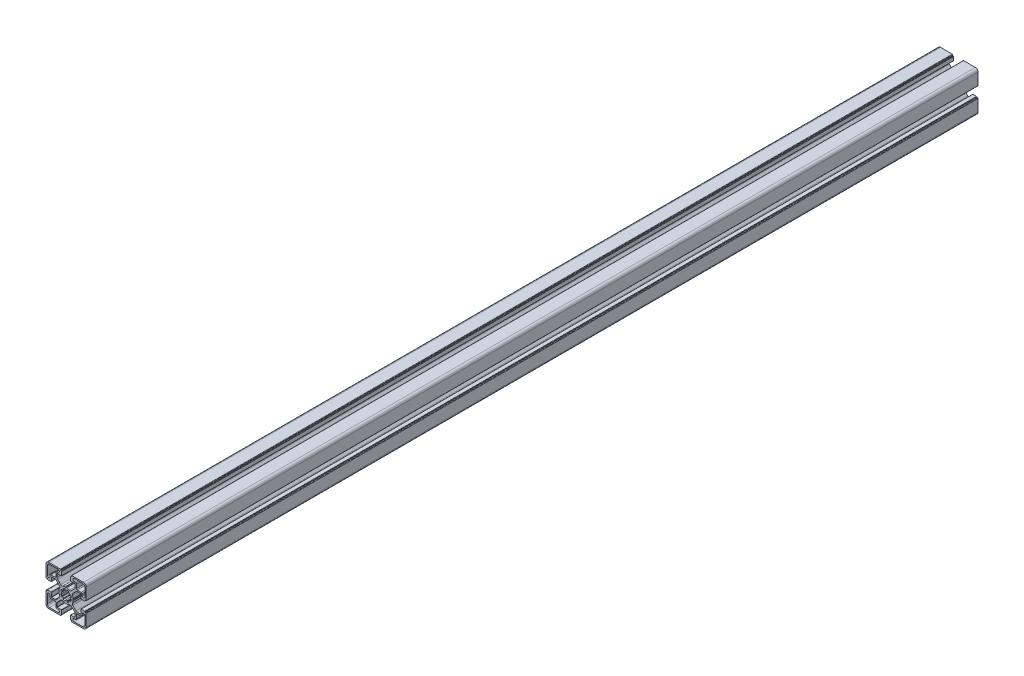
from build123d import *

# Parameters (mm, degrees)
BOSS_EXTRU_1_DEPTH = 1000


with BuildPart() as part:
    # Esquisse2 → Boss.-Extru.1 (new body)
    with BuildSketch(Plane.XY):
        with BuildLine():
            Line((-192.464705439, -351.135013575), (-192.030789329, -350.389251613))
            ThreePointArc((-192.030789329, -350.389251613), (-192.008099493, -350.33058749), (-192.004751867, -350.267777448))
            ThreePointArc((-192.004751867, -350.267777448), (-192.285035172, -348.883447185), (-192.804402464, -347.569983587))
            ThreePointArc((-192.804402464, -347.569983587), (-192.985908697, -346.38788866), (-192.44128198, -345.323147062))
            Line((-192.44128198, -345.323147062), (-188.874986025, -341.756855105))
            ThreePointArc((-188.874986025, -341.756855105), (-188.244141301, -341.335338521), (-187.500009401, -341.187321592))
            Line((-187.500009401, -341.187321592), (-183.687863463, -341.187321592))
            ThreePointArc((-183.687863463, -341.187321592), (-183.546441859, -341.245900338), (-183.487863113, -341.387321941))
            Line((-183.487863113, -341.387321941), (-183.487863113, -345.981828905))
            ThreePointArc((-183.487863113, -345.981828905), (-183.429284366, -346.12325051), (-183.287862762, -346.181829256))
            Line((-183.287862762, -346.181829256), (-179.285166009, -346.181829256))
            ThreePointArc((-179.285166009, -346.181829256), (-179.073034487, -346.093961503), (-178.985166733, -345.88182998))
            Line((-178.985166733, -345.88182998), (-178.985166733, -345.681839032))
            ThreePointArc((-178.985166733, -345.681839032), (-178.897298833, -345.469707156), (-178.685166958, -345.381839256))
            Line((-178.685166958, -345.381839256), (-178.0047864, -345.381839256))
            ThreePointArc((-178.0047864, -345.381839256), (-177.651233276, -345.235392756), (-177.504786776, -344.881839631))
            Line((-177.504786776, -344.881839631), (-177.504786776, -331.681827015))
            ThreePointArc((-177.504786776, -331.681827015), (-178.383465776, -329.560508257), (-180.504784534, -328.681829257))
            Line((-180.504784534, -328.681829257), (-193.629056903, -328.681829257))
            ThreePointArc((-193.629056903, -328.681829257), (-193.982610029, -328.828275756), (-194.129056529, -329.181828882))
            Line((-194.129056529, -329.181828882), (-194.129056529, -329.881829981))
            ThreePointArc((-194.129056529, -329.881829981), (-194.216924283, -330.093961503), (-194.429055805, -330.181829256))
            Line((-194.429055805, -330.181829256), (-194.70476714, -330.181829256))
            ThreePointArc((-194.70476714, -330.181829256), (-194.916898308, -330.269696863), (-195.004765915, -330.481828031))
            Line((-195.004765915, -330.481828031), (-195.004765915, -334.515030698))
            ThreePointArc((-195.004765915, -334.515030698), (-194.946187022, -334.656452656), (-194.804765065, -334.715031549))
            Line((-194.804765065, -334.715031549), (-190.099380697, -334.715031549))
            ThreePointArc((-190.099380697, -334.715031549), (-189.957959093, -334.773610295), (-189.899380347, -334.9150319))
            Line((-189.899380347, -334.9150319), (-189.899380347, -338.710260175))
            ThreePointArc((-189.899380347, -338.710260175), (-190.051621327, -339.47562727), (-190.48516696, -340.124474162))
            Line((-190.48516696, -340.124474162), (-194.059867926, -343.699175128))
            ThreePointArc((-194.059867926, -343.699175128), (-195.150164081, -344.214009408), (-196.338266679, -344.008553194))
            ThreePointArc((-196.338266679, -344.008553194), (-197.695629231, -343.467994797), (-199.128369878, -343.181829256))
            ThreePointArc((-199.128369878, -343.181829256), (-199.191201005, -343.184754557), (-199.250016338, -343.207049503))
            Line((-199.250016338, -343.207049503), (-199.892137456, -343.574906197))
            ThreePointArc((-199.892137456, -343.574906197), (-199.941802013, -343.622754392), (-200.004765916, -343.650889155))
            ThreePointArc((-200.004765916, -343.650889155), (-200.067729818, -343.622754392), (-200.117394375, -343.574906197))
            Line((-200.117394375, -343.574906197), (-200.759515492, -343.207049503))
            ThreePointArc((-200.759515492, -343.207049503), (-200.818330825, -343.184754557), (-200.881161953, -343.181829255))
            ThreePointArc((-200.881161953, -343.181829255), (-202.3139026, -343.467994797), (-203.671265152, -344.008553193))
            ThreePointArc((-203.671265152, -344.008553193), (-204.85936775, -344.214009407), (-205.949663904, -343.699175128))
            Line((-205.949663904, -343.699175128), (-209.52436487, -340.124474162))
            ThreePointArc((-209.52436487, -340.124474162), (-209.957910503, -339.475627269), (-210.110151485, -338.710260174))
            Line((-210.110151485, -338.710260174), (-210.110151485, -334.915031899))
            ThreePointArc((-210.110151485, -334.915031899), (-210.051572738, -334.773610295), (-209.910151134, -334.715031548))
            Line((-209.910151134, -334.715031548), (-205.204766766, -334.715031548))
            ThreePointArc((-205.204766766, -334.715031548), (-205.063344808, -334.656452656), (-205.004765915, -334.515030698))
            Line((-205.004765915, -334.515030698), (-205.004765915, -330.481828032))
            ThreePointArc((-205.004765915, -330.481828032), (-205.092633523, -330.269696863), (-205.304764692, -330.181829256))
            Line((-205.304764692, -330.181829256), (-205.580476025, -330.181829256))
            ThreePointArc((-205.580476025, -330.181829256), (-205.792607548, -330.093961502), (-205.880475302, -329.88182998))
            Line((-205.880475302, -329.88182998), (-205.880475302, -329.181828882))
            ThreePointArc((-205.880475302, -329.181828882), (-206.026921801, -328.828275756), (-206.380474927, -328.681829256))
            Line((-206.380474927, -328.681829256), (-219.504747296, -328.681829256))
            ThreePointArc((-219.504747296, -328.681829256), (-221.626066055, -329.560508256), (-222.504745055, -331.681827014))
            Line((-222.504745055, -331.681827014), (-222.504745055, -344.88183963))
            ThreePointArc((-222.504745055, -344.88183963), (-222.358298555, -345.235392756), (-222.00474543, -345.381839256))
            Line((-222.00474543, -345.381839256), (-221.324364871, -345.381839256))
            ThreePointArc((-221.324364871, -345.381839256), (-221.112232996, -345.469707157), (-221.024365096, -345.681839032))
            Line((-221.024365096, -345.681839032), (-221.024365096, -345.88182998))
            ThreePointArc((-221.024365096, -345.88182998), (-220.936497342, -346.093961503), (-220.724365819, -346.181829256))
            Line((-220.724365819, -346.181829256), (-216.721669067, -346.181829256))
            ThreePointArc((-216.721669067, -346.181829256), (-216.580247463, -346.12325051), (-216.521668717, -345.981828906))
            Line((-216.521668717, -345.981828906), (-216.521668717, -341.387321942))
            ThreePointArc((-216.521668717, -341.387321942), (-216.46308997, -341.245900338), (-216.321668366, -341.187321592))
            Line((-216.321668366, -341.187321592), (-212.509522428, -341.187321592))
            ThreePointArc((-212.509522428, -341.187321592), (-211.765390527, -341.335338522), (-211.134545803, -341.756855106))
            Line((-211.134545803, -341.756855106), (-207.568249848, -345.323147062))
            ThreePointArc((-207.568249848, -345.323147062), (-207.023623131, -346.38788866), (-207.205129364, -347.569983588))
            ThreePointArc((-207.205129364, -347.569983588), (-207.724496656, -348.883447186), (-208.004779961, -350.267777448))
            ThreePointArc((-208.004779961, -350.267777448), (-208.001432335, -350.33058749), (-207.978742499, -350.389251614))
            Line((-207.978742499, -350.389251614), (-207.54482639, -351.135013575))
            ThreePointArc((-207.54482639, -351.135013575), (-207.5390619, -351.158167493), (-207.536095855, -351.181843132))
            ThreePointArc((-207.536095855, -351.181843132), (-207.5390619, -351.20551877), (-207.54482639, -351.228672687))
            Line((-207.54482639, -351.228672687), (-207.978742499, -351.974434649))
            ThreePointArc((-207.978742499, -351.974434649), (-208.001432335, -352.033098773), (-208.004779962, -352.095908815))
            ThreePointArc((-208.004779962, -352.095908815), (-207.724496656, -353.480239077), (-207.205129364, -354.793702675))
            ThreePointArc((-207.205129364, -354.793702675), (-207.023623132, -355.975797603), (-207.568249848, -357.040539202))
            Line((-207.568249848, -357.040539202), (-211.134545804, -360.606831158))
            ThreePointArc((-211.134545804, -360.606831158), (-211.765390528, -361.028347742), (-212.509522429, -361.176364671))
            Line((-212.509522429, -361.176364671), (-216.321668366, -361.176364671))
            ThreePointArc((-216.321668366, -361.176364671), (-216.463089971, -361.117785925), (-216.521668717, -360.97636432))
            Line((-216.521668717, -360.97636432), (-216.521668717, -356.381857357))
            ThreePointArc((-216.521668717, -356.381857357), (-216.580247463, -356.240435753), (-216.721669067, -356.181857007))
            Line((-216.721669067, -356.181857007), (-220.72436582, -356.181857007))
            ThreePointArc((-220.72436582, -356.181857007), (-220.936497342, -356.26972476), (-221.024365096, -356.481856283))
            Line((-221.024365096, -356.481856283), (-221.024365096, -356.68184723))
            ThreePointArc((-221.024365096, -356.68184723), (-221.112232996, -356.893979106), (-221.324364871, -356.981847005))
            Line((-221.324364871, -356.981847005), (-222.004745429, -356.981847005))
            ThreePointArc((-222.004745429, -356.981847005), (-222.358298555, -357.128293506), (-222.504745055, -357.481846632))
            Line((-222.504745055, -357.481846632), (-222.504745055, -370.681859247))
            ThreePointArc((-222.504745055, -370.681859247), (-221.626066055, -372.803178006), (-219.504747296, -373.681857006))
            Line((-219.504747296, -373.681857006), (-206.380474927, -373.681857006))
            ThreePointArc((-206.380474927, -373.681857006), (-206.026921801, -373.535410506), (-205.880475301, -373.18185738))
            Line((-205.880475301, -373.18185738), (-205.880475301, -372.481856282))
            ThreePointArc((-205.880475301, -372.481856282), (-205.792607548, -372.269724759), (-205.580476025, -372.181857005))
            Line((-205.580476025, -372.181857005), (-205.304764691, -372.181857005))
            ThreePointArc((-205.304764691, -372.181857005), (-205.092633522, -372.093989398), (-205.004765915, -371.881858229))
            Line((-205.004765915, -371.881858229), (-205.004765915, -367.848655563))
            ThreePointArc((-205.004765915, -367.848655563), (-205.063344808, -367.707233605), (-205.204766766, -367.648654712))
            Line((-205.204766766, -367.648654712), (-209.910151134, -367.648654712))
            ThreePointArc((-209.910151134, -367.648654712), (-210.051572738, -367.590075966), (-210.110151485, -367.448654362))
            Line((-210.110151485, -367.448654362), (-210.110151485, -363.653426086))
            ThreePointArc((-210.110151485, -363.653426086), (-209.957910503, -362.888058992), (-209.524364871, -362.239212099))
            Line((-209.524364871, -362.239212099), (-205.949663905, -358.664511133))
            ThreePointArc((-205.949663905, -358.664511133), (-204.85936775, -358.149676855), (-203.671265152, -358.355133067))
            ThreePointArc((-203.671265152, -358.355133067), (-202.3139026, -358.895691464), (-200.881161954, -359.181857005))
            ThreePointArc((-200.881161954, -359.181857005), (-200.818330826, -359.178931703), (-200.759515493, -359.156636757))
            Line((-200.759515493, -359.156636757), (-200.117394376, -358.788780064))
            ThreePointArc((-200.117394376, -358.788780064), (-200.067729819, -358.740931869), (-200.004765916, -358.712797106))
            ThreePointArc((-200.004765916, -358.712797106), (-199.941802013, -358.740931869), (-199.892137456, -358.788780064))
            Line((-199.892137456, -358.788780064), (-199.250016339, -359.156636758))
            ThreePointArc((-199.250016339, -359.156636758), (-199.191201006, -359.178931704), (-199.128369878, -359.181857005))
            ThreePointArc((-199.128369878, -359.181857005), (-197.695629231, -358.895691464), (-196.338266679, -358.355133068))
            ThreePointArc((-196.338266679, -358.355133068), (-195.150164082, -358.149676855), (-194.059867927, -358.664511133))
            Line((-194.059867927, -358.664511133), (-190.48516696, -362.239212099))
            ThreePointArc((-190.48516696, -362.239212099), (-190.051621328, -362.888058992), (-189.899380348, -363.653426086))
            Line((-189.899380348, -363.653426086), (-189.899380348, -367.448654362))
            ThreePointArc((-189.899380348, -367.448654362), (-189.957959094, -367.590075965), (-190.099380697, -367.648654712))
            Line((-190.099380697, -367.648654712), (-194.804765066, -367.648654712))
            ThreePointArc((-194.804765066, -367.648654712), (-194.946187023, -367.707233605), (-195.004765916, -367.848655563))
            Line((-195.004765916, -367.848655563), (-195.004765916, -371.881858229))
            ThreePointArc((-195.004765916, -371.881858229), (-194.916898309, -372.093989397), (-194.70476714, -372.181857004))
            Line((-194.70476714, -372.181857004), (-194.429055806, -372.181857004))
            ThreePointArc((-194.429055806, -372.181857004), (-194.216924283, -372.269724758), (-194.12905653, -372.48185628))
            Line((-194.12905653, -372.48185628), (-194.12905653, -373.181857379))
            ThreePointArc((-194.12905653, -373.181857379), (-193.98261003, -373.535410505), (-193.629056903, -373.681857006))
            Line((-193.629056903, -373.681857006), (-180.504784534, -373.681857006))
            ThreePointArc((-180.504784534, -373.681857006), (-178.383465775, -372.803178005), (-177.504786775, -370.681859246))
            Line((-177.504786775, -370.681859246), (-177.504786775, -357.481846631))
            ThreePointArc((-177.504786775, -357.481846631), (-177.651233275, -357.128293504), (-178.004786402, -356.981847004))
            Line((-178.004786402, -356.981847004), (-178.685166959, -356.981847004))
            ThreePointArc((-178.685166959, -356.981847004), (-178.897298836, -356.893979105), (-178.985166735, -356.681847228))
            Line((-178.985166735, -356.681847228), (-178.985166735, -356.481856281))
            ThreePointArc((-178.985166735, -356.481856281), (-179.073034488, -356.269724759), (-179.28516601, -356.181857005))
            Line((-179.28516601, -356.181857005), (-183.287862762, -356.181857005))
            ThreePointArc((-183.287862762, -356.181857005), (-183.429284367, -356.240435752), (-183.487863113, -356.381857356))
            Line((-183.487863113, -356.381857356), (-183.487863113, -360.97636432))
            ThreePointArc((-183.487863113, -360.97636432), (-183.546441859, -361.117785924), (-183.687863463, -361.176364671))
            Line((-183.687863463, -361.176364671), (-187.500009401, -361.176364671))
            ThreePointArc((-187.500009401, -361.176364671), (-188.244141302, -361.028347742), (-188.874986026, -360.606831157))
            Line((-188.874986026, -360.606831157), (-192.441281982, -357.040539201))
            ThreePointArc((-192.441281982, -357.040539201), (-192.985908698, -355.975797602), (-192.804402465, -354.793702674))
            ThreePointArc((-192.804402465, -354.793702674), (-192.285035173, -353.480239077), (-192.004751867, -352.095908814))
            ThreePointArc((-192.004751867, -352.095908814), (-192.008099493, -352.033098772), (-192.030789329, -351.974434649))
            Line((-192.030789329, -351.974434649), (-192.464705438, -351.228672687))
            ThreePointArc((-192.464705438, -351.228672687), (-192.47046993, -351.20551877), (-192.473435973, -351.181843131))
            ThreePointArc((-192.473435973, -351.181843131), (-192.47046993, -351.158167492), (-192.464705439, -351.135013575))
        make_face()
        with BuildLine():
            Line((-195.08422015, -352.069665956), (-194.515035218, -352.16805429))
            ThreePointArc((-194.515035218, -352.16805429), (-194.165013852, -352.386136153), (-194.09791825, -352.793042574))
            ThreePointArc((-194.09791825, -352.793042574), (-194.353505931, -353.535154011), (-194.702268027, -354.238303673))
            ThreePointArc((-194.702268027, -354.238303673), (-195.035805071, -354.480613812), (-195.437988264, -354.390005633))
            Line((-195.437988264, -354.390005633), (-195.915053025, -354.058342475))
            ThreePointArc((-195.915053025, -354.058342475), (-196.474632965, -354.722769754), (-197.140765494, -355.280318651))
            Line((-197.140765494, -355.280318651), (-196.813454008, -355.744441346))
            ThreePointArc((-196.813454008, -355.744441346), (-196.720150548, -356.146118205), (-196.960380945, -356.481288596))
            ThreePointArc((-196.960380945, -356.481288596), (-197.665869942, -356.825320826), (-198.409694498, -357.075915978))
            ThreePointArc((-198.409694498, -357.075915978), (-198.816910196, -357.011432294), (-199.037244235, -356.662956066))
            Line((-199.037244235, -356.662956066), (-199.137377178, -356.106032077))
            ThreePointArc((-199.137377178, -356.106032077), (-200.004765915, -356.181843131), (-200.872154653, -356.106032077))
            Line((-200.872154653, -356.106032077), (-200.972287596, -356.662956066))
            ThreePointArc((-200.972287596, -356.662956066), (-201.192621634, -357.011432294), (-201.599837332, -357.075915978))
            ThreePointArc((-201.599837332, -357.075915978), (-202.343661888, -356.825320826), (-203.049150885, -356.481288596))
            ThreePointArc((-203.049150885, -356.481288596), (-203.289381283, -356.146118205), (-203.196077822, -355.744441346))
            Line((-203.196077822, -355.744441346), (-202.868766337, -355.280318651))
            ThreePointArc((-202.868766337, -355.280318651), (-203.534898866, -354.722769754), (-204.094478805, -354.058342475))
            Line((-204.094478805, -354.058342475), (-204.571543566, -354.390005633))
            ThreePointArc((-204.571543566, -354.390005633), (-204.97372676, -354.480613812), (-205.307263804, -354.238303673))
            ThreePointArc((-205.307263804, -354.238303673), (-205.6560259, -353.535154011), (-205.91161358, -352.793042574))
            ThreePointArc((-205.91161358, -352.793042574), (-205.844517979, -352.386136153), (-205.494496613, -352.16805429))
            Line((-205.494496613, -352.16805429), (-204.925311681, -352.069665956))
            ThreePointArc((-204.925311681, -352.069665956), (-205.004765916, -351.18184313), (-204.925311681, -350.294020305))
            Line((-204.925311681, -350.294020305), (-205.494496613, -350.195631971))
            ThreePointArc((-205.494496613, -350.195631971), (-205.844517979, -349.977550108), (-205.91161358, -349.570643686))
            ThreePointArc((-205.91161358, -349.570643686), (-205.6560259, -348.82853225), (-205.307263804, -348.125382588))
            ThreePointArc((-205.307263804, -348.125382588), (-204.97372676, -347.883072448), (-204.571543566, -347.973680627))
            Line((-204.571543566, -347.973680627), (-204.094478805, -348.305343785))
            ThreePointArc((-204.094478805, -348.305343785), (-203.534898866, -347.640916506), (-202.868766337, -347.08336761))
            Line((-202.868766337, -347.08336761), (-203.196077822, -346.619244915))
            ThreePointArc((-203.196077822, -346.619244915), (-203.289381283, -346.217568056), (-203.049150885, -345.882397665))
            ThreePointArc((-203.049150885, -345.882397665), (-202.343661888, -345.538365434), (-201.599837332, -345.287770282))
            ThreePointArc((-201.599837332, -345.287770282), (-201.192621634, -345.352253967), (-200.972287596, -345.700730195))
            Line((-200.972287596, -345.700730195), (-200.872154653, -346.257654184))
            ThreePointArc((-200.872154653, -346.257654184), (-200.004765915, -346.18184313), (-199.137377178, -346.257654184))
            Line((-199.137377178, -346.257654184), (-199.037244235, -345.700730195))
            ThreePointArc((-199.037244235, -345.700730195), (-198.816910196, -345.352253967), (-198.409694498, -345.287770282))
            ThreePointArc((-198.409694498, -345.287770282), (-197.665869942, -345.538365434), (-196.960380945, -345.882397665))
            ThreePointArc((-196.960380945, -345.882397665), (-196.720150548, -346.217568056), (-196.813454008, -346.619244915))
            Line((-196.813454008, -346.619244915), (-197.140765494, -347.08336761))
            ThreePointArc((-197.140765494, -347.08336761), (-196.474632965, -347.640916506), (-195.915053025, -348.305343785))
            Line((-195.915053025, -348.305343785), (-195.437988264, -347.973680627))
            ThreePointArc((-195.437988264, -347.973680627), (-195.035805071, -347.883072448), (-194.702268027, -348.125382588))
            ThreePointArc((-194.702268027, -348.125382588), (-194.353505931, -348.82853225), (-194.09791825, -349.570643686))
            ThreePointArc((-194.09791825, -349.570643686), (-194.165013852, -349.977550108), (-194.515035218, -350.195631971))
            Line((-194.515035218, -350.195631971), (-195.08422015, -350.294020305))
            ThreePointArc((-195.08422015, -350.294020305), (-195.004765915, -351.18184313), (-195.08422015, -352.069665956))
        make_face(mode=Mode.SUBTRACT)
        with BuildLine():
            Line((-191.004786777, -330.181829255), (-181.504784909, -330.181829255))
            ThreePointArc((-181.504784909, -330.181829255), (-179.737019277, -330.914061756), (-179.004786777, -332.681827388))
            Line((-179.004786777, -332.681827388), (-179.004786777, -342.181638256))
            ThreePointArc((-179.004786777, -342.181638256), (-180.504786777, -343.681638255), (-182.004786777, -342.181638255))
            Line((-182.004786777, -342.181638255), (-182.004786777, -340.631829508))
            ThreePointArc((-182.004786777, -340.631829508), (-182.297679777, -339.924723255), (-183.00478603, -339.631830255))
            Line((-183.00478603, -339.631830255), (-187.454788523, -339.631830255))
            ThreePointArc((-187.454788523, -339.631830255), (-188.161894777, -339.338937255), (-188.454787777, -338.631831002))
            Line((-188.454787777, -338.631831002), (-188.454787777, -334.181828508))
            ThreePointArc((-188.454787777, -334.181828508), (-188.747680777, -333.474722255), (-189.45478703, -333.181829255))
            Line((-189.45478703, -333.181829255), (-191.004786777, -333.181829255))
            ThreePointArc((-191.004786777, -333.181829255), (-192.504786777, -331.681829255), (-191.004786777, -330.181829255))
        make_face(mode=Mode.SUBTRACT)
        with BuildLine():
            Line((-221.004745053, -332.681827388), (-221.004745053, -342.181638256))
            ThreePointArc((-221.004745053, -342.181638256), (-219.504745053, -343.681638255), (-218.004745054, -342.181638255))
            Line((-218.004745054, -342.181638255), (-218.004745054, -340.631829508))
            ThreePointArc((-218.004745054, -340.631829508), (-217.711852054, -339.924723255), (-217.0047458, -339.631830255))
            Line((-217.0047458, -339.631830255), (-212.554743307, -339.631830255))
            ThreePointArc((-212.554743307, -339.631830255), (-211.847637054, -339.338937255), (-211.554744054, -338.631831002))
            Line((-211.554744054, -338.631831002), (-211.554744054, -334.181828508))
            ThreePointArc((-211.554744054, -334.181828508), (-211.261851054, -333.474722255), (-210.554744801, -333.181829255))
            Line((-210.554744801, -333.181829255), (-209.004745053, -333.181829255))
            ThreePointArc((-209.004745053, -333.181829255), (-207.504745054, -331.681829255), (-209.004745053, -330.181829255))
            Line((-209.004745053, -330.181829255), (-218.504746922, -330.181829255))
            ThreePointArc((-218.504746922, -330.181829255), (-220.272512554, -330.914061756), (-221.004745053, -332.681827388))
        make_face(mode=Mode.SUBTRACT)
        with BuildLine():
            Line((-191.004786777, -372.181857005), (-181.504784909, -372.181857005))
            ThreePointArc((-181.504784909, -372.181857005), (-179.737019277, -371.449624505), (-179.004786777, -369.681858873))
            Line((-179.004786777, -369.681858873), (-179.004786777, -360.182048004))
            ThreePointArc((-179.004786777, -360.182048004), (-180.504786777, -358.682048005), (-182.004786777, -360.182048005))
            Line((-182.004786777, -360.182048005), (-182.004786777, -361.731856752))
            ThreePointArc((-182.004786777, -361.731856752), (-182.297679777, -362.438963006), (-183.00478603, -362.731856006))
            Line((-183.00478603, -362.731856006), (-187.454788523, -362.731856006))
            ThreePointArc((-187.454788523, -362.731856006), (-188.161894777, -363.024749005), (-188.454787777, -363.731855258))
            Line((-188.454787777, -363.731855258), (-188.454787777, -368.181857752))
            ThreePointArc((-188.454787777, -368.181857752), (-188.747680777, -368.888964005), (-189.45478703, -369.181857005))
            Line((-189.45478703, -369.181857005), (-191.004786777, -369.181857005))
            ThreePointArc((-191.004786777, -369.181857005), (-192.504786777, -370.681857005), (-191.004786777, -372.181857005))
        make_face(mode=Mode.SUBTRACT)
        with BuildLine():
            Line((-209.004745053, -372.181857005), (-218.504746922, -372.181857005))
            ThreePointArc((-218.504746922, -372.181857005), (-220.272512554, -371.449624505), (-221.004745053, -369.681858873))
            Line((-221.004745053, -369.681858873), (-221.004745053, -360.182048004))
            ThreePointArc((-221.004745053, -360.182048004), (-219.504745053, -358.682048005), (-218.004745054, -360.182048005))
            Line((-218.004745054, -360.182048005), (-218.004745054, -361.731856752))
            ThreePointArc((-218.004745054, -361.731856752), (-217.711852054, -362.438963006), (-217.0047458, -362.731856006))
            Line((-217.0047458, -362.731856006), (-212.554743307, -362.731856006))
            ThreePointArc((-212.554743307, -362.731856006), (-211.847637054, -363.024749005), (-211.554744054, -363.731855258))
            Line((-211.554744054, -363.731855258), (-211.554744054, -368.181857752))
            ThreePointArc((-211.554744054, -368.181857752), (-211.261851054, -368.888964005), (-210.554744801, -369.181857005))
            Line((-210.554744801, -369.181857005), (-209.004745053, -369.181857005))
            ThreePointArc((-209.004745053, -369.181857005), (-207.504745054, -370.681857005), (-209.004745053, -372.181857005))
        make_face(mode=Mode.SUBTRACT)
    extrude(amount=BOSS_EXTRU_1_DEPTH)


solid = part.part
